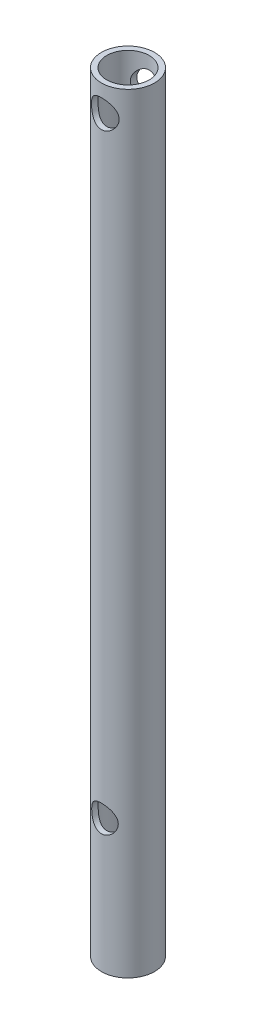
from build123d import *

# Parameters (mm, degrees)
SZKIC1_R                    = 5
SZKIC1_R_2                  = 4
DODANIE_WYCI_GNI_CIE1_DEPTH = 145
SZKIC2_R                    = 2.605682129
SZKIC2_R_2                  = 2.5
WYTNIJ_WYCI_GNI_CIE1_DEPTH  = 15


with BuildPart() as part:
    # Szkic1 → Dodanie-wyciągnięcie1 (new body)
    with BuildSketch(Plane(origin=(0, 0, 0), x_dir=(1, 0, 0), z_dir=(0, 1, 0))):
        Circle(SZKIC1_R)
        Circle(SZKIC1_R_2, mode=Mode.SUBTRACT)
    extrude(amount=DODANIE_WYCI_GNI_CIE1_DEPTH)

    # Szkic2 → Wytnij-wyciągnięcie1 (cut, symmetric)
    with BuildSketch(Plane.XY):
        with Locations((0, 140)):
            Circle(SZKIC2_R)
        with Locations((1.33e-07, 25)):
            Circle(SZKIC2_R_2)
    extrude(amount=WYTNIJ_WYCI_GNI_CIE1_DEPTH, both=True, mode=Mode.SUBTRACT)


solid = part.part
